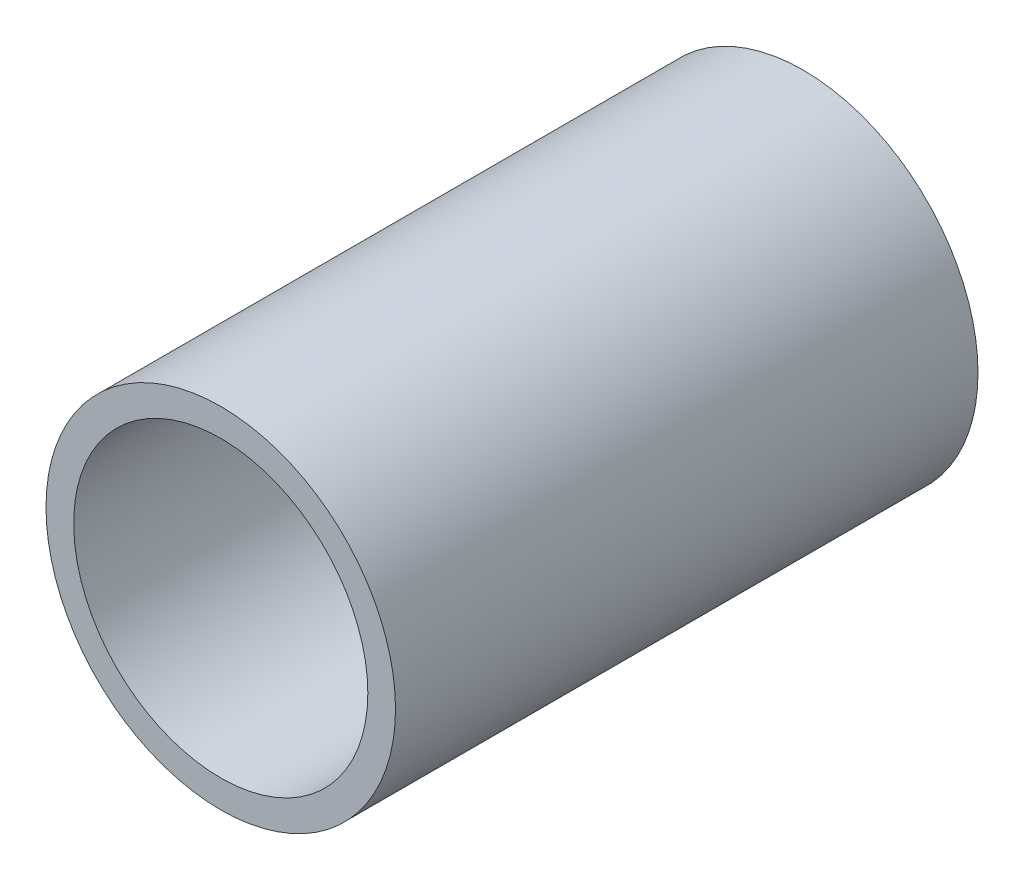
from build123d import *

# Parameters (mm, degrees)
SKETCH1_R                                           = 9.525
BOSS_EXTRUDE1_DEPTH                                 = 31.75
F_17_32_0_53125_DIAMETER_HOLE3_D                    = 16.03375
F_17_32_0_53125_DIAMETER_HOLE3_DEPTH                = 25.4
F_17_32_0_53125_DIAMETER_HOLE3_TIP                  = 4.817024475
CSK_FOR_1_4_FLAT_HEAD_MACHINE_SCREW_100_D           = 6.7564
CSK_FOR_1_4_FLAT_HEAD_MACHINE_SCREW_100_DEPTH       = 25.4
CSK_FOR_1_4_FLAT_HEAD_MACHINE_SCREW_100_CSINK_D     = 12.8778
CSK_FOR_1_4_FLAT_HEAD_MACHINE_SCREW_100_CSINK_ANGLE = 100
CSK_FOR_1_4_FLAT_HEAD_MACHINE_SCREW_100_TIP         = 2.029827343


with BuildPart() as part:
    # Sketch1 → Boss-Extrude1 (new body)
    with BuildSketch(Plane.XY):
        Circle(SKETCH1_R)
    extrude(amount=BOSS_EXTRUDE1_DEPTH)

    # 17/32 (0.53125) Diameter Hole3
    with Locations(Plane.XY.offset(31.75)):
        with Locations((0, 0)):
            Hole(F_17_32_0_53125_DIAMETER_HOLE3_D / 2, depth=F_17_32_0_53125_DIAMETER_HOLE3_DEPTH)
            with Locations((0, 0, -(F_17_32_0_53125_DIAMETER_HOLE3_DEPTH + F_17_32_0_53125_DIAMETER_HOLE3_TIP / 2))):  # 118° drill point
                Cone(0, F_17_32_0_53125_DIAMETER_HOLE3_D / 2, F_17_32_0_53125_DIAMETER_HOLE3_TIP, mode=Mode.SUBTRACT)

    # CSK for 1/4 Flat Head Machine Screw (100)1
    with Locations(Plane(origin=(0, 0, 0), x_dir=(-1, 0, 0), z_dir=(0, 0, -1))):
        with Locations((0, 0)):
            CounterSinkHole(CSK_FOR_1_4_FLAT_HEAD_MACHINE_SCREW_100_D / 2, CSK_FOR_1_4_FLAT_HEAD_MACHINE_SCREW_100_CSINK_D / 2, depth=CSK_FOR_1_4_FLAT_HEAD_MACHINE_SCREW_100_DEPTH, counter_sink_angle=CSK_FOR_1_4_FLAT_HEAD_MACHINE_SCREW_100_CSINK_ANGLE)
            with Locations((0, 0, -(CSK_FOR_1_4_FLAT_HEAD_MACHINE_SCREW_100_DEPTH + CSK_FOR_1_4_FLAT_HEAD_MACHINE_SCREW_100_TIP / 2))):  # 118° drill point
                Cone(0, CSK_FOR_1_4_FLAT_HEAD_MACHINE_SCREW_100_D / 2, CSK_FOR_1_4_FLAT_HEAD_MACHINE_SCREW_100_TIP, mode=Mode.SUBTRACT)


solid = part.part
